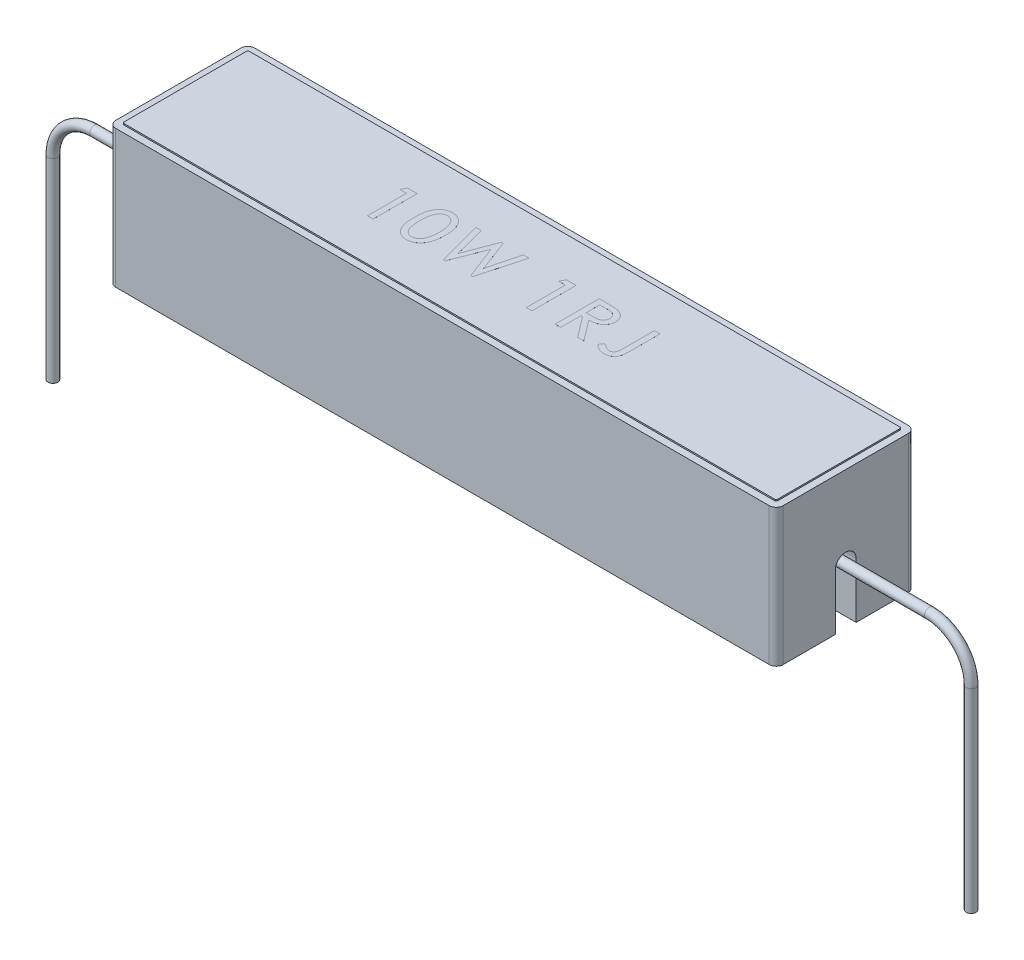
from build123d import *

# Parameters (mm, degrees)
SKETCH1_W               = 48
SKETCH1_H               = 10
BOSS_EXTRUDE1_DEPTH     = 10
CUT_EXTRUDE1_DEPTH      = 2
SKETCH3_W               = 44
SKETCH3_H               = 6
CUT_EXTRUDE2_DEPTH      = 8
FILLET4_R               = 0.5
SKETCH7_OUTSIDE_W       = 60.008
SKETCH7_OUTSIDE_H       = 22.008
SKETCH7_OUTSIDE_W_2     = 47
SKETCH7_OUTSIDE_H_2     = 9
CUT_EXTRUDE4_DEPTH      = 0.1
FILLET5_R               = 0.1
SKETCH4_W               = 44
SKETCH4_H               = 6
BOSS_EXTRUDE2_DEPTH     = 7.5
FILLET2_R               = 0.5
FILLET3_R               = 0.1
SKETCH6_R               = 0.35
CUT_EXTRUDE3_DEPTH      = 25
CUT_EXTRUDE3_DEPTH_BACK = 25
SKETCH_WIRE_DIAMETER_R  = 0.35
BOSS_EXTRUDE3_DEPTH     = 0.001


with BuildPart() as part:
    # Sketch1 → Boss-Extrude1 (new body)
    with BuildSketch(Plane(origin=(0, 0, 0), x_dir=(1, 0, 0), z_dir=(0, 1, 0))):
        Rectangle(SKETCH1_W, SKETCH1_H)
    extrude(amount=BOSS_EXTRUDE1_DEPTH)

    # Sketch2 → Cut-Extrude1 (cut)
    with BuildSketch(Plane(origin=(24, 0, 0), x_dir=(0, 0, -1), z_dir=(1, 0, 0))):
        with BuildLine():
            Line((-0.75, 0), (-0.75, 4))
            ThreePointArc((-0.75, 4), (0, 4.75), (0.75, 4))
            Line((0.75, 4), (0.75, 0))
            ThreePointArc((0.75, 0), (0, -0.75), (-0.75, 0))
        make_face()
    cut_extrude1 = extrude(amount=-CUT_EXTRUDE1_DEPTH, mode=Mode.SUBTRACT)

    # Mirror1: Cut-Extrude1 across plane
    add(cut_extrude1.mirror(Plane(origin=(0, 0, 0), x_dir=(0, 0, 1), z_dir=(1, 0, 0))), mode=Mode.SUBTRACT)

    # Sketch3 → Cut-Extrude2 (cut)
    with BuildSketch(Plane.XZ):
        Rectangle(SKETCH3_W, SKETCH3_H)
    extrude(amount=-CUT_EXTRUDE2_DEPTH, mode=Mode.SUBTRACT)

    # Fillet4
    fillet4_edges = [part.edges().sort_by_distance(p)[0] for p in [
        (24, 5, 5),
        (-24, 5, 5),
        (-24, 5, -5),
        (24, 5, -5),
    ]]
    fillet(fillet4_edges, radius=FILLET4_R)

    # Sketch7 outside → Cut-Extrude4 (cut)
    with BuildSketch(Plane(origin=(0, 10, 0), x_dir=(1, 0, 0), z_dir=(0, 1, 0))):
        Rectangle(SKETCH7_OUTSIDE_W, SKETCH7_OUTSIDE_H)
        Rectangle(SKETCH7_OUTSIDE_W_2, SKETCH7_OUTSIDE_H_2, mode=Mode.SUBTRACT)
    extrude(amount=-CUT_EXTRUDE4_DEPTH, mode=Mode.SUBTRACT)

    # Fillet5
    fillet5_edges = [part.edges().sort_by_distance(p)[0] for p in [
        (23.5, 9.95, 4.5),
        (-23.5, 9.95, 4.5),
        (-23.5, 9.95, -4.5),
        (23.5, 9.95, -4.5),
    ]]
    fillet(fillet5_edges, radius=FILLET5_R)

    # Sketch10 → Boss-Extrude3 (add)
    with BuildSketch(Plane(origin=(0, 10, 0), x_dir=(1, 0, 0), z_dir=(0, 1, 0))):
        Polygon((-9.184625401, 1.675), (-8.493910256, 1.675), (-8.493910256, -1.5), (-8.900961538, -1.5), (-8.900961538, 1.308653846), (-9.389423077, 1.308653846), align=None)
        with BuildLine():
            add(Edge.make_bspline(
                [(-7.122147436, 0.086227965), (-7.121844398, 0.136691609), (-7.121255886, 0.234693977), (-7.114914413, 0.377262321), (-7.103974902, 0.511084116), (-7.089923485, 0.636163333), (-7.070483723, 0.752585908), (-7.048240608, 0.860409375), (-7.020860014, 0.959646997), (-6.988878543, 1.050475854), (-6.952969783, 1.134509098), (-6.91348793, 1.212799323), (-6.870683042, 1.286340527), (-6.824844221, 1.355107094), (-6.773804344, 1.417567003), (-6.7205598, 1.475859326), (-6.663111379, 1.52884615), (-6.601985546, 1.576262201), (-6.53875416, 1.619130846), (-6.472669554, 1.655263397), (-6.405262937, 1.686738291), (-6.335674723, 1.71219875), (-6.264409459, 1.731976672), (-6.19121192, 1.745788697), (-6.11643017, 1.755300246), (-6.065751972, 1.756038976), (-6.04028145, 1.756410256)],
                knots=[0, 0, 0, 0, 0.000151384, 0.000293994, 0.000427995, 0.000554141, 0.000671458, 0.000781979, 0.000884285, 0.000980035, 0.001070647, 0.001158253, 0.001242904, 0.001325813, 0.001405873, 0.001484639, 0.001562506, 0.001639988, 0.001716546, 0.001791418, 0.001865691, 0.001939537, 0.002013449, 0.002087293, 0.00216287, 0.002239234, 0.002239234, 0.002239234, 0.002239234], degree=3))
            add(Edge.make_bspline(
                [(-6.04028145, 1.756410256), (-6.012495893, 1.755678553), (-5.957652137, 1.754234299), (-5.876261359, 1.746374585), (-5.797599424, 1.730495348), (-5.720587052, 1.710582166), (-5.646471653, 1.683360415), (-5.573785093, 1.65205665), (-5.504764622, 1.6124075), (-5.437056091, 1.569036717), (-5.372981027, 1.519021639), (-5.311695771, 1.464676755), (-5.255111057, 1.404146996), (-5.20116427, 1.339515179), (-5.15262257, 1.268250057), (-5.10641228, 1.192847027), (-5.065496018, 1.1114282), (-5.026675414, 1.02543387), (-4.993306796, 0.932577451), (-4.963105005, 0.833389219), (-4.938629758, 0.726633406), (-4.918326719, 0.612641784), (-4.902680345, 0.491222441), (-4.891125098, 0.362663794), (-4.885092148, 0.226845651), (-4.883951213, 0.133934441), (-4.883365385, 0.086227965)],
                knots=[0, 0, 0, 0, 8.3379e-05, 0.000164575, 0.000244905, 0.000323894, 0.000402958, 0.000481549, 0.000560993, 0.000641436, 0.0007226, 0.000804574, 0.000886906, 0.000970947, 0.001056868, 0.00114533, 0.001236069, 0.001330029, 0.00142822, 0.001531844, 0.001640916, 0.001756568, 0.001879084, 0.002008069, 0.00214369, 0.002286816, 0.002286816, 0.002286816, 0.002286816], degree=3))
            add(Edge.make_bspline(
                [(-4.883365385, 0.086227965), (-4.883957353, 0.038734228), (-4.885110112, -0.053751745), (-4.89105648, -0.188945032), (-4.902911223, -0.316804495), (-4.917507504, -0.437689004), (-4.93798113, -0.551231426), (-4.962910119, -0.657491743), (-4.990865964, -0.757028642), (-5.02504063, -0.848969766), (-5.06288189, -0.934862538), (-5.103937105, -1.015553341), (-5.149152841, -1.091201188), (-5.199218228, -1.16098531), (-5.251747617, -1.22710153), (-5.309023074, -1.287251944), (-5.370000775, -1.342583057), (-5.434533236, -1.392390209), (-5.501881818, -1.437306256), (-5.572469012, -1.475220827), (-5.644515478, -1.508873784), (-5.719629822, -1.534377751), (-5.796289402, -1.556143294), (-5.875785049, -1.570202673), (-5.957378811, -1.579511182), (-6.0124824, -1.580773456), (-6.04028145, -1.581410256)],
                knots=[0, 0, 0, 0, 0.000142491, 0.000277476, 0.000405827, 0.000527631, 0.000642657, 0.00075173, 0.000854994, 0.000952587, 0.001045709, 0.001136448, 0.001224036, 0.001309802, 0.001393934, 0.001477165, 0.001558667, 0.001640723, 0.001721515, 0.001801208, 0.001880901, 0.001959752, 0.002038907, 0.002119744, 0.00220164, 0.002285019, 0.002285019, 0.002285019, 0.002285019], degree=3))
            add(Edge.make_bspline(
                [(-6.04028145, -1.581410256), (-6.065956135, -1.580973994), (-6.116806679, -1.580109944), (-6.191895666, -1.571635645), (-6.265043115, -1.557571271), (-6.336034188, -1.537859451), (-6.40536768, -1.512833014), (-6.472742916, -1.482516984), (-6.53771706, -1.445807979), (-6.600910175, -1.404562324), (-6.661404481, -1.357648425), (-6.717750755, -1.304623976), (-6.771303743, -1.246756186), (-6.821002525, -1.183421024), (-6.867945375, -1.115027347), (-6.910263656, -1.040930796), (-6.949718025, -0.961922749), (-6.98629718, -0.877394652), (-7.019324708, -0.785877873), (-7.045667137, -0.685581966), (-7.070507791, -0.577601349), (-7.088737254, -0.460843653), (-7.104553671, -0.336189721), (-7.113729678, -0.202830351), (-7.121571282, -0.061207835), (-7.121951864, 0.03618166), (-7.122147436, 0.086227965)],
                knots=[0, 0, 0, 0, 7.7e-05, 0.000152504, 0.000226348, 0.00030026, 0.000373292, 0.0004473, 0.000521616, 0.00059694, 0.00067353, 0.000750931, 0.000828798, 0.000909852, 0.000992236, 0.001077436, 0.001165611, 0.001257058, 0.00135362, 0.001457152, 0.001567943, 0.001685888, 0.001811479, 0.001944795, 0.0020868, 0.002236912, 0.002236912, 0.002236912, 0.002236912], degree=3))
        make_face()
        with BuildLine():
            add(Edge.make_bspline(
                [(-6.715096154, 0.0875), (-6.714932658, 0.04488181), (-6.714616143, -0.037623816), (-6.709916397, -0.157013078), (-6.703225227, -0.268183127), (-6.693216315, -0.37110382), (-6.679869756, -0.465928196), (-6.664072782, -0.552525302), (-6.64606186, -0.631061044), (-6.624103521, -0.701664473), (-6.599789939, -0.765995204), (-6.572756364, -0.825219734), (-6.544686474, -0.880679808), (-6.513066599, -0.931276165), (-6.479580369, -0.977700241), (-6.443623121, -1.019775325), (-6.406478474, -1.058423684), (-6.353490939, -1.10133904), (-6.285598026, -1.146207), (-6.201317054, -1.185113885), (-6.116400998, -1.21079627), (-6.05911142, -1.213650611), (-6.030741186, -1.215064103)],
                knots=[0, 0, 0, 0, 0.000127846, 0.0002475, 0.000358388, 0.000461924, 0.000557627, 0.000645575, 0.00072595, 0.000799178, 0.000867217, 0.000932119, 0.000994416, 0.001053542, 0.001110917, 0.001165969, 0.001219489, 0.001271444, 0.001370232, 0.001462717, 0.001549295, 0.001634229, 0.001634229, 0.001634229, 0.001634229], degree=3))
            add(Edge.make_bspline(
                [(-6.030741186, -1.215064103), (-5.998591999, -1.213381946), (-5.934493694, -1.2100281), (-5.840092309, -1.185607862), (-5.749576923, -1.144621934), (-5.677856666, -1.0983171), (-5.623669115, -1.053279996), (-5.584535882, -1.014939933), (-5.548466315, -0.972135898), (-5.514415467, -0.925519693), (-5.483626652, -0.874328742), (-5.453939149, -0.819724888), (-5.428090527, -0.760398097), (-5.413151396, -0.719056517), (-5.405535857, -0.697981771)],
                knots=[0, 0, 0, 0, 9.6394e-05, 0.000192188, 0.000290411, 0.000393438, 0.000447184, 0.000501604, 0.000557552, 0.000614927, 0.000674594, 0.000736625, 0.000801268, 0.000868487, 0.000868487, 0.000868487, 0.000868487], degree=3))
            add(Edge.make_bspline(
                [(-5.405535857, -0.697981771), (-5.39636089, -0.670292546), (-5.377657084, -0.613846143), (-5.354223786, -0.525962836), (-5.3348239, -0.433746831), (-5.318119517, -0.337689231), (-5.305435854, -0.237306101), (-5.296668779, -0.132694131), (-5.291639858, -0.023852679), (-5.290828929, 0.049969852), (-5.290416667, 0.0875)],
                knots=[0, 0, 0, 0, 8.7496e-05, 0.000178366, 0.000272673, 0.000370125, 0.000470786, 0.000576106, 0.000684984, 0.000797576, 0.000797576, 0.000797576, 0.000797576], degree=3))
            add(Edge.make_bspline(
                [(-5.290416667, 0.0875), (-5.290515339, 0.125033991), (-5.290707765, 0.198231556), (-5.296426894, 0.305301686), (-5.303343571, 0.407218161), (-5.315276119, 0.503646281), (-5.328630511, 0.595067271), (-5.346948045, 0.680834786), (-5.366594652, 0.761805047), (-5.391138987, 0.836977996), (-5.417973267, 0.9071119), (-5.446275726, 0.972440209), (-5.476877701, 1.033015195), (-5.510593845, 1.088076798), (-5.546179881, 1.138533299), (-5.583768577, 1.184081248), (-5.623920036, 1.224464267), (-5.68005314, 1.269996982), (-5.752415758, 1.317386663), (-5.842899168, 1.359916405), (-5.936332345, 1.384988968), (-5.999435829, 1.388381221), (-6.030741186, 1.390064103)],
                knots=[0, 0, 0, 0, 0.000112582, 0.000219554, 0.000321603, 0.000418953, 0.000510974, 0.000598663, 0.000681962, 0.000760808, 0.000835696, 0.000907185, 0.000974315, 0.001039107, 0.001100696, 0.00115941, 0.001216076, 0.001271208, 0.001375995, 0.001474744, 0.00157008, 0.00166394, 0.00166394, 0.00166394, 0.00166394], degree=3))
            add(Edge.make_bspline(
                [(-6.030741186, 1.390064103), (-6.05910324, 1.388622993), (-6.116580744, 1.385702493), (-6.201625672, 1.360376792), (-6.285603242, 1.321161415), (-6.353041204, 1.276262399), (-6.405590526, 1.233392556), (-6.44324228, 1.19562325), (-6.478027767, 1.153310417), (-6.511596968, 1.107260024), (-6.542249381, 1.056330878), (-6.572020987, 1.001452028), (-6.598251846, 0.941716779), (-6.622920449, 0.877336763), (-6.644647505, 0.806604298), (-6.663436879, 0.72818842), (-6.680227457, 0.641687061), (-6.69232837, 0.546671316), (-6.70250081, 0.443594266), (-6.710113785, 0.332249986), (-6.714558837, 0.212620605), (-6.714913139, 0.130117096), (-6.715096154, 0.0875)],
                knots=[0, 0, 0, 0, 8.4934e-05, 0.000172124, 0.000264032, 0.000362288, 0.000414244, 0.000467312, 0.000521954, 0.000578442, 0.000638109, 0.000700139, 0.000765621, 0.00083366, 0.000906888, 0.000987411, 0.001075476, 0.001171093, 0.001274629, 0.001386194, 0.001505848, 0.001633694, 0.001633694, 0.001633694, 0.001633694], degree=3))
        make_face(mode=Mode.SUBTRACT)
        Polygon((-4.285, 1.675), (-3.880492788, 1.675), (-3.298536659, -0.59367488), (-2.436732772, 1.675), (-2.303805088, 1.675), (-1.448361378, -0.589222756), (-0.86322516, 1.675), (-0.458717949, 1.675), (-1.322429888, -1.5), (-1.461081731, -1.5), (-2.373767027, 0.867257612), (-3.292176482, -1.5), (-3.42955629, -1.5), align=None)
        Polygon((2.245374599, 1.675), (2.936089744, 1.675), (2.936089744, -1.5), (2.529038462, -1.5), (2.529038462, 1.308653846), (2.040576923, 1.308653846), align=None)
        with BuildLine():
            Line((4.592788462, 1.675), (5.242798478, 1.675))
            add(Edge.make_bspline(
                [(5.242798478, 1.675), (5.284564967, 1.674899012), (5.364498541, 1.674705739), (5.479196884, 1.672677606), (5.583339928, 1.669991523), (5.677006382, 1.664380685), (5.760447074, 1.65942808), (5.83330111, 1.651282433), (5.895911491, 1.644017397), (5.93355479, 1.636024399), (5.950686098, 1.632386819)],
                knots=[0, 0, 0, 0, 0.000125297, 0.000239796, 0.000344152, 0.000437784, 0.000521299, 0.000594838, 0.000657714, 0.000710227, 0.000710227, 0.000710227, 0.000710227], degree=3))
            add(Edge.make_bspline(
                [(5.950686098, 1.632386819), (5.976230183, 1.625965358), (6.026555921, 1.613314103), (6.099060141, 1.588406463), (6.167510615, 1.559042142), (6.231817124, 1.525382646), (6.292134286, 1.487258907), (6.347295168, 1.443520822), (6.399472777, 1.396402571), (6.446653848, 1.344425872), (6.489581487, 1.28915479), (6.526285742, 1.230599066), (6.557778316, 1.169545104), (6.584062415, 1.106083663), (6.603715469, 1.039507055), (6.617481295, 0.970305274), (6.626955056, 0.898683846), (6.627679285, 0.849904175), (6.628044872, 0.825280449)],
                knots=[0, 0, 0, 0, 7.8989e-05, 0.000155621, 0.000229697, 0.000302242, 0.000373169, 0.000443399, 0.000513179, 0.000583857, 0.000653697, 0.000722868, 0.000790854, 0.000859594, 0.000928615, 0.000998716, 0.001071136, 0.001144957, 0.001144957, 0.001144957, 0.001144957], degree=3))
            add(Edge.make_bspline(
                [(6.628044872, 0.825280449), (6.626683926, 0.784670434), (6.624009206, 0.704858036), (6.599701312, 0.588457626), (6.559867508, 0.478733192), (6.514432925, 0.393019093), (6.470233246, 0.3292959), (6.43322842, 0.283993598), (6.392545633, 0.241552333), (6.348473352, 0.201530251), (6.299851745, 0.165695956), (6.248164086, 0.131719436), (6.192800648, 0.100485431), (6.112997218, 0.062981262), (6.005058404, 0.023891342), (5.865593206, -0.009620511), (5.7148905, -0.029976637), (5.610693225, -0.033037732), (5.556991186, -0.034615385)],
                knots=[0, 0, 0, 0, 0.000121719, 0.000239219, 0.000354906, 0.000470998, 0.000529043, 0.000587352, 0.000646283, 0.000705282, 0.000765703, 0.000827269, 0.000890775, 0.000956211, 0.001091623, 0.001234314, 0.001385787, 0.001546881, 0.001546881, 0.001546881, 0.001546881], degree=3))
            Line((5.556991186, -0.034615385), (6.66875, -1.5))
            Line((6.66875, -1.5), (6.220357572, -1.5))
            Line((6.220357572, -1.5), (5.108598758, -0.034615385))
            Line((5.108598758, -0.034615385), (4.999839744, -0.034615385))
            Line((4.999839744, -0.034615385), (4.999839744, -1.5))
            Line((4.999839744, -1.5), (4.592788462, -1.5))
            Line((4.592788462, -1.5), (4.592788462, 1.675))
        make_face()
        with BuildLine():
            Line((4.999839744, 1.308653846), (4.999839744, 0.331094752))
            Line((4.999839744, 0.331094752), (5.466676683, 0.327914663))
            add(Edge.make_bspline(
                [(5.466676683, 0.327914663), (5.49169572, 0.327979307), (5.540052166, 0.328104251), (5.610047283, 0.330676993), (5.674969444, 0.334985125), (5.734562201, 0.341365723), (5.788652705, 0.348977993), (5.837655578, 0.357503798), (5.881110691, 0.369016358), (5.931871721, 0.385611294), (5.988267865, 0.412272628), (6.048093721, 0.452865617), (6.100533196, 0.500906425), (6.143536281, 0.557197752), (6.177943348, 0.618955537), (6.202973702, 0.684894265), (6.218051799, 0.754642262), (6.220001831, 0.802309573), (6.22099359, 0.826552484)],
                knots=[0, 0, 0, 0, 7.5053e-05, 0.000145061, 0.000210087, 0.00027021, 0.000324808, 0.000373959, 0.000419312, 0.000459538, 0.000534079, 0.000605523, 0.000675733, 0.000746466, 0.000817075, 0.000887124, 0.000957354, 0.001030038, 0.001030038, 0.001030038, 0.001030038], degree=3))
            add(Edge.make_bspline(
                [(6.22099359, 0.826552484), (6.219954913, 0.849938216), (6.217894736, 0.896322937), (6.203241876, 0.96439843), (6.177050335, 1.028621044), (6.14230012, 1.088908225), (6.099242924, 1.143105826), (6.049726165, 1.190863263), (5.992524039, 1.228717679), (5.939860823, 1.254266865), (5.89266302, 1.270290356), (5.850871342, 1.28018579), (5.803302862, 1.288923204), (5.749860388, 1.296602654), (5.690642689, 1.302213341), (5.625502049, 1.305743192), (5.554470615, 1.30851665), (5.505052881, 1.30860696), (5.479397035, 1.308653846)],
                knots=[0, 0, 0, 0, 7.0147e-05, 0.000139133, 0.000207635, 0.000277452, 0.000347182, 0.000414666, 0.000482933, 0.000552061, 0.000589672, 0.000632247, 0.000680772, 0.00073474, 0.000794166, 0.000859152, 0.000930432, 0.001007392, 0.001007392, 0.001007392, 0.001007392], degree=3))
            Line((5.479397035, 1.308653846), (4.999839744, 1.308653846))
        make_face(mode=Mode.SUBTRACT)
        with BuildLine():
            Line((8.569679487, 1.675), (8.976730769, 1.675))
            Line((8.976730769, 1.675), (8.976730769, -0.456295072))
            add(Edge.make_bspline(
                [(8.976730769, -0.456295072), (8.976422832, -0.494880828), (8.975830537, -0.569097824), (8.973120962, -0.676020119), (8.966587309, -0.773776858), (8.958221265, -0.862830753), (8.94886935, -0.943231461), (8.935145255, -1.014645937), (8.920465412, -1.077325134), (8.896709796, -1.148415075), (8.85924704, -1.228223562), (8.799578838, -1.314284608), (8.725475022, -1.390948758), (8.653497014, -1.446911845), (8.589483538, -1.485341964), (8.538611777, -1.511849247), (8.484439061, -1.533374751), (8.427458754, -1.55026531), (8.368275894, -1.56442727), (8.306249712, -1.574712835), (8.241388073, -1.580310902), (8.197195401, -1.581039556), (8.17471254, -1.581410256)],
                knots=[0, 0, 0, 0, 0.000115762, 0.00022266, 0.000320813, 0.000409606, 0.000491018, 0.000563494, 0.000627665, 0.000683981, 0.000788109, 0.000890965, 0.000996676, 0.001106847, 0.001163349, 0.001220523, 0.001278749, 0.001337902, 0.001398684, 0.001461212, 0.001526338, 0.001593782, 0.001593782, 0.001593782, 0.001593782], degree=3))
            add(Edge.make_bspline(
                [(8.17471254, -1.581410256), (8.143065931, -1.580636006), (8.080094369, -1.579095375), (7.986253009, -1.564071651), (7.893468594, -1.541594748), (7.800068146, -1.508302588), (7.704141298, -1.461605258), (7.604368334, -1.397095357), (7.497126682, -1.317613395), (7.426505447, -1.255487209), (7.389230769, -1.222696314)],
                knots=[0, 0, 0, 0, 9.4871e-05, 0.000188778, 0.000284418, 0.000380979, 0.000485658, 0.000603707, 0.00073689, 0.000885762, 0.000885762, 0.000885762, 0.000885762], degree=3))
            Line((7.389230769, -1.222696314), (7.590848357, -0.930128205))
            add(Edge.make_bspline(
                [(7.590848357, -0.930128205), (7.614338797, -0.944825534), (7.659683312, -0.973196362), (7.725774861, -1.013010728), (7.786569517, -1.049513083), (7.842901826, -1.081116765), (7.89360029, -1.109850069), (7.939202302, -1.134835754), (7.980310646, -1.155278622), (8.006147684, -1.16740554), (8.018252204, -1.173086939)],
                knots=[0, 0, 0, 0, 8.3126e-05, 0.000160462, 0.000231471, 0.000295844, 0.000354223, 0.000406303, 0.000451812, 0.000491927, 0.000491927, 0.000491927, 0.000491927], degree=3))
            add(Edge.make_bspline(
                [(8.018252204, -1.173086939), (8.033390693, -1.179594154), (8.062353026, -1.19204349), (8.106043204, -1.204291411), (8.146759229, -1.213627763), (8.173393154, -1.214598671), (8.186160857, -1.215064103)],
                knots=[0, 0, 0, 0, 4.9368e-05, 9.4449e-05, 0.000135986, 0.000174231, 0.000174231, 0.000174231, 0.000174231], degree=3))
            add(Edge.make_bspline(
                [(8.186160857, -1.215064103), (8.205108487, -1.214226636), (8.242638872, -1.21256783), (8.297311387, -1.198721663), (8.349002667, -1.176016767), (8.397368438, -1.144747011), (8.441069482, -1.105553962), (8.478456891, -1.058850267), (8.509278057, -1.005814103), (8.528152956, -0.955500689), (8.541115319, -0.909362915), (8.547843643, -0.866187292), (8.555168364, -0.815581187), (8.560803494, -0.757224127), (8.564121472, -0.691003687), (8.56754755, -0.617024613), (8.569326616, -0.535381829), (8.569558709, -0.478344323), (8.569679487, -0.448662861)],
                knots=[0, 0, 0, 0, 5.678e-05, 0.000112467, 0.000168005, 0.000225518, 0.000284517, 0.00034332, 0.000404302, 0.000467729, 0.000503987, 0.000547905, 0.000598635, 0.000657428, 0.000723683, 0.00079753, 0.000879598, 0.000968643, 0.000968643, 0.000968643, 0.000968643], degree=3))
            Line((8.569679487, -0.448662861), (8.569679487, 1.675))
        make_face()
    extrude(amount=BOSS_EXTRUDE3_DEPTH)


with BuildPart() as body_2:
    # Sketch4 → Boss-Extrude2 (new body)
    with BuildSketch(Plane.XZ.offset(-8)):
        Rectangle(SKETCH4_W, SKETCH4_H)
    extrude(amount=BOSS_EXTRUDE2_DEPTH)

    # Fillet2
    fillet2_edges = [body_2.edges().sort_by_distance(p)[0] for p in [
        (-22, 0.5, 0),
        (0, 0.5, 3),
        (22, 0.5, 0),
        (0, 0.5, -3),
    ]]
    fillet(fillet2_edges, radius=FILLET2_R)

    # Fillet3
    fillet3_edges = [body_2.edges().sort_by_distance(p)[0] for p in [
        (22, 4.5, -3),
        (-22, 4.5, -3),
        (-22, 4.5, 3),
        (22, 4.5, 3),
        (21.823024454, 0.618351992, 2.823024454),
        (-21.823024454, 0.618351992, 2.823024454),
        (21.823024454, 0.618351992, -2.823024454),
        (-21.823024454, 0.618351992, -2.823024454),
    ]]
    fillet(fillet3_edges, radius=FILLET3_R)

    # Sketch6 → Cut-Extrude3 (cut, two sides)
    with BuildSketch(Plane(origin=(0, 0, 0), x_dir=(0, 0, -1), z_dir=(1, 0, 0))) as cut_extrude3_sk:
        with Locations((0, 4)):
            Circle(SKETCH6_R)
    extrude(amount=CUT_EXTRUDE3_DEPTH, mode=Mode.SUBTRACT)
    extrude(cut_extrude3_sk.sketch, amount=-CUT_EXTRUDE3_DEPTH_BACK, mode=Mode.SUBTRACT)


with BuildPart() as body_3:
    # Adjust Wire Size Length: sweep along a path in Sketch Adjust Wire Length
    with BuildLine(Plane.XY) as adjust_wire_size_length_path:
        Line((-33.02, -13), (-33.02, 1))
        ThreePointArc((-33.02, 1), (-32.141320344, 3.121320344), (-30.02, 4))
        Line((-30.02, 4), (30.02, 4))
        ThreePointArc((30.02, 4), (32.141320344, 3.121320344), (33.02, 1))
        Line((33.02, 1), (33.02, -13))
    # Sketch Wire Diameter → Adjust Wire Size Length (sweep)
    with BuildSketch(Plane(origin=(0, 0, 0), x_dir=(0, 0, -1), z_dir=(1, 0, 0))):
        with Locations((0, 4)):
            Circle(SKETCH_WIRE_DIAMETER_R)
    sweep(path=adjust_wire_size_length_path.line)


solid = Compound([part.part, body_2.part, body_3.part])
